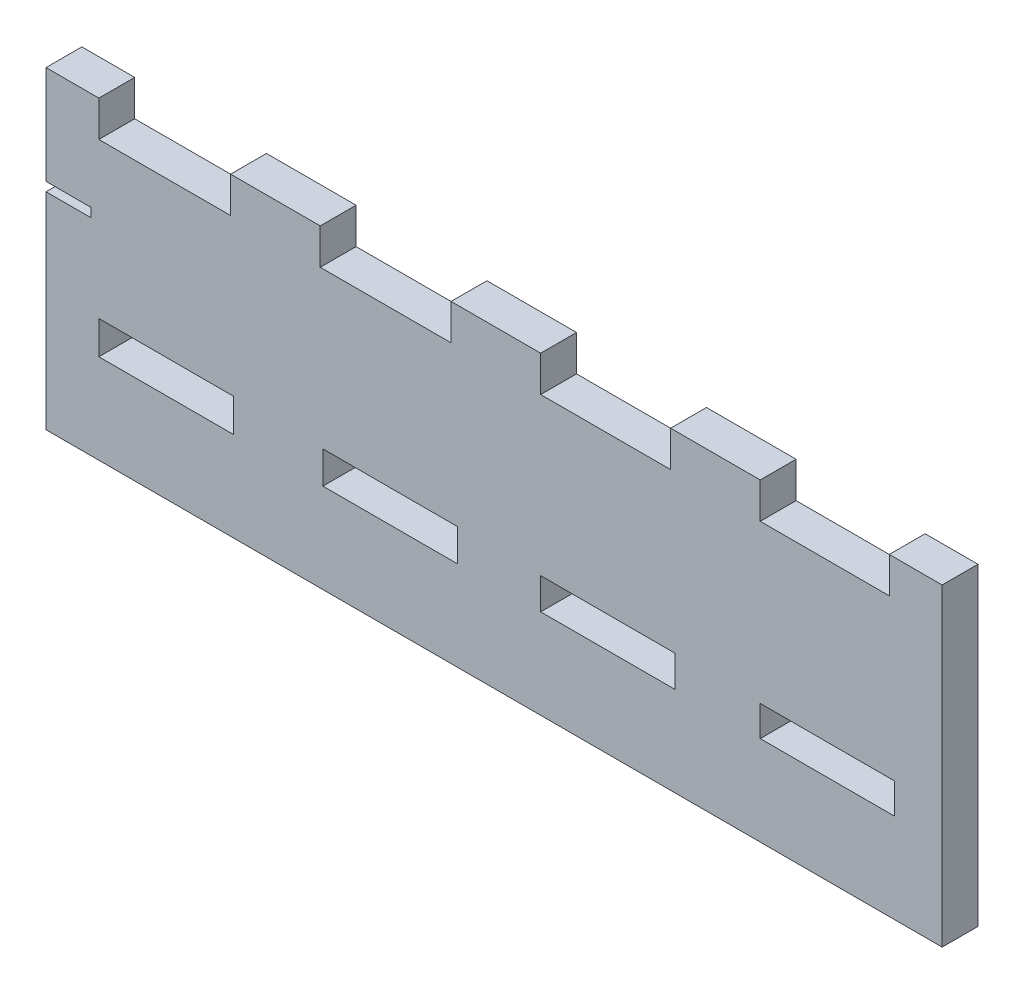
from build123d import *

# Parameters (mm, degrees)
SKIZZE1_W                       = 15
SKIZZE1_H                       = 3.7
SKIZZE1_H_2                     = 3.6
SKIZZE1_H_3                     = 3.5
SKIZZE1_H_4                     = 3.4
AUFSATZ_LINEAR_AUSTRAGEN1_DEPTH = 4


with BuildPart() as part:
    # Skizze1 → Aufsatz-Linear austragen1 (new body)
    with BuildSketch(Plane.XY):
        Polygon((5.9, 35), (5.9, 31), (20.6, 31), (20.6, 35), (30.6, 35), (30.6, 31), (45.2, 31), (45.2, 35), (55.2, 35), (55.2, 31), (69.7, 31), (69.7, 35), (79.7, 35), (79.7, 31), (94.1, 31), (94.1, 35), (100, 35), (100, 0), (0, 0), (0, 23), (5, 23), (5, 24), (0, 24), (0, 35), align=None)
        with Locations((13.4, 11.85)):
            Rectangle(SKIZZE1_W, SKIZZE1_H, mode=Mode.SUBTRACT)
        with Locations((38.4, 11.8)):
            Rectangle(SKIZZE1_W, SKIZZE1_H_2, mode=Mode.SUBTRACT)
        with Locations((62.7, 11.75)):
            Rectangle(SKIZZE1_W, SKIZZE1_H_3, mode=Mode.SUBTRACT)
        with Locations((87.2, 11.7)):
            Rectangle(SKIZZE1_W, SKIZZE1_H_4, mode=Mode.SUBTRACT)
    extrude(amount=AUFSATZ_LINEAR_AUSTRAGEN1_DEPTH)


solid = part.part
